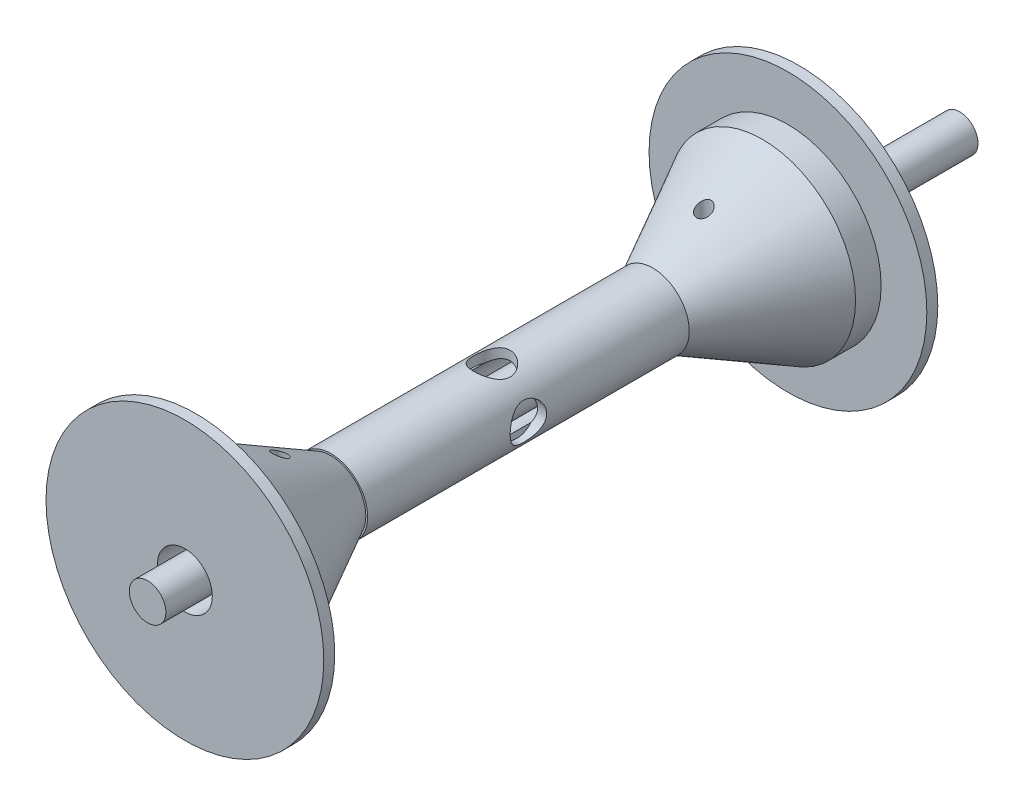
from build123d import *

# Parameters (mm, degrees)
SKETCH1_R               = 6.35
BOSS_EXTRUDE1_DEPTH     = 282.194
SKETCH15_W              = 3.81
SKETCH15_H              = 25.4
SKETCH18_W              = 3.175
SKETCH18_H              = 111.76
SKETCH16_R              = 2.54
CUT_EXTRUDE1_DEPTH      = 49.26
CUT_EXTRUDE1_DEPTH_BACK = 49.26
CUT_EXTRUDE2_START      = 25.4
SKETCH19_R              = 6.35
CUT_EXTRUDE2_DEPTH      = 17.78
CUT_EXTRUDE3_START      = 25.4
SKETCH20_R              = 6.35
CUT_EXTRUDE3_DEPTH      = 16.764


with BuildPart() as part:
    # Sketch1 → Boss-Extrude1 (new body)
    with BuildSketch(Plane.XY):
        Circle(SKETCH1_R)
    extrude(amount=BOSS_EXTRUDE1_DEPTH)


with BuildPart() as body_2:
    # Sketch14 → Revolve1 (revolve)
    with BuildSketch(Plane(origin=(0, 0, 0), x_dir=(0, 0, -1), z_dir=(1, 0, 0))):
        Polygon((-106.68, 9.525), (-55.88, 9.525), (-55.88, 32.385), (-68.58, 32.385), (-106.68, 12.065), align=None)
    revolve(axis=Axis((0, 0, 282.194), (0, 0, -1)))


with BuildPart() as body_3:
    # Sketch15 → Revolve2 (revolve)
    with BuildSketch(Plane(origin=(0, 0, 0), x_dir=(0, 0, -1), z_dir=(1, 0, 0))):
        with Locations((-57.785, 35.56)):
            Rectangle(SKETCH15_W, SKETCH15_H)
    revolve(axis=Axis((0, 0, 282.194), (0, 0, -1)))

    # Combine1: union body 2
    add(body_2.part)


with BuildPart() as body_3_2:
    # Mirror4: mirrored copy
    add(body_3.part.mirror(Plane(origin=(0, 0, 162.56), x_dir=(1, 0, 0), z_dir=(0, 0, -1))))


with BuildPart() as body_3_1:
    add(body_3.part)

    add(body_3_2.part)  # Revolve4 merges body 3 2
    # Sketch18 → Revolve4 (revolve)
    with BuildSketch(Plane(origin=(0, 0, 0), x_dir=(1, 0, 0), z_dir=(0, 1, 0))):
        with Locations((-11.1125, -162.56)):
            Rectangle(SKETCH18_W, SKETCH18_H)
    revolve(axis=Axis((0, 0, 282.194), (0, 0, -1)))


with BuildPart() as cut_extrude1_tool:
    # Sketch16 → Cut-Extrude1 (new body, two sides)
    with BuildSketch(Plane(origin=(0, 0, 0), x_dir=(1, 0, 0), z_dir=(0, 1, 0))) as cut_extrude1_sk:
        with Locations((0, -88.9)):
            Circle(SKETCH16_R)
        with Locations((0, -236.22)):
            Circle(SKETCH16_R)
    extrude(amount=CUT_EXTRUDE1_DEPTH)
    extrude(cut_extrude1_sk.sketch, amount=-CUT_EXTRUDE1_DEPTH_BACK)


with BuildPart() as part_1:
    add(part.part)

    # Cut-Extrude1: cut by cut_extrude1_tool
    add(cut_extrude1_tool.part, mode=Mode.SUBTRACT)


with BuildPart() as body_3_3:
    add(body_3_1.part)

    # Cut-Extrude1: cut by cut_extrude1_tool
    add(cut_extrude1_tool.part, mode=Mode.SUBTRACT)

    # Sketch19 → Cut-Extrude2 (cut)
    with BuildSketch(Plane(origin=(0, 0, 0), x_dir=(1, 0, 0), z_dir=(0, 1, 0)).offset(CUT_EXTRUDE2_START)):
        with Locations((0, -162.56)):
            Circle(SKETCH19_R)
    extrude(amount=-CUT_EXTRUDE2_DEPTH, mode=Mode.SUBTRACT)

    # Sketch20 → Cut-Extrude3 (cut)
    with BuildSketch(Plane(origin=(0, 0, 0), x_dir=(0, 0, -1), z_dir=(1, 0, 0)).offset(CUT_EXTRUDE3_START)):
        with Locations((-162.56, 0)):
            Circle(SKETCH20_R)
    extrude(amount=-CUT_EXTRUDE3_DEPTH, mode=Mode.SUBTRACT)


solid = Compound([part_1.part, body_3_3.part])
